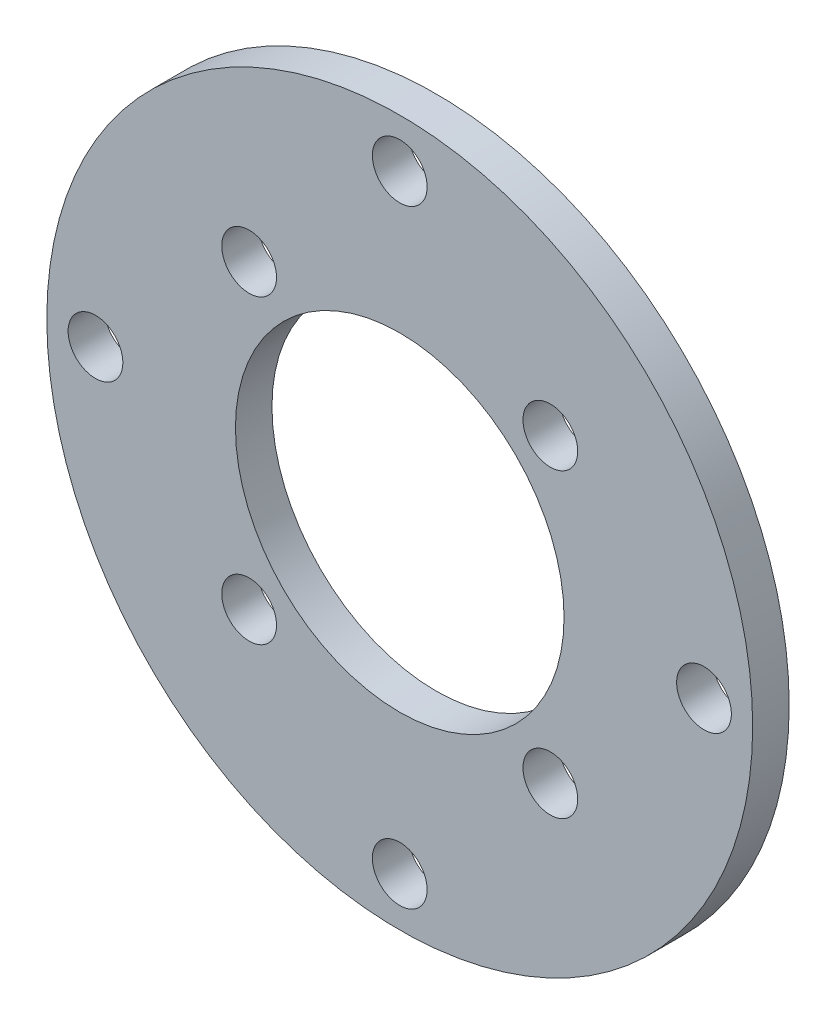
from build123d import *

# Parameters (mm, degrees)
SKETCH1_R           = 29
SKETCH1_R_2         = 13.5
SKETCH1_R_3         = 2.25
BOSS_EXTRUDE1_DEPTH = 3


with BuildPart() as part:
    # Sketch1 → Boss-Extrude1 (new body)
    with BuildSketch(Plane.XY):
        Circle(SKETCH1_R)
        Circle(SKETCH1_R_2, mode=Mode.SUBTRACT)
        with Locations((-12.374368671, 12.374368671)):
            Circle(SKETCH1_R_3, mode=Mode.SUBTRACT)
        with Locations((12.374368671, 12.374368671)):
            Circle(SKETCH1_R_3, mode=Mode.SUBTRACT)
        with Locations((12.374368671, -12.374368671)):
            Circle(SKETCH1_R_3, mode=Mode.SUBTRACT)
        with Locations((-12.374368671, -12.374368671)):
            Circle(SKETCH1_R_3, mode=Mode.SUBTRACT)
        with Locations((0, 25)):
            Circle(SKETCH1_R_3, mode=Mode.SUBTRACT)
        with Locations((25, 0)):
            Circle(SKETCH1_R_3, mode=Mode.SUBTRACT)
        with Locations((0, -25)):
            Circle(SKETCH1_R_3, mode=Mode.SUBTRACT)
        with Locations((-25, 0)):
            Circle(SKETCH1_R_3, mode=Mode.SUBTRACT)
    extrude(amount=BOSS_EXTRUDE1_DEPTH)


solid = part.part
